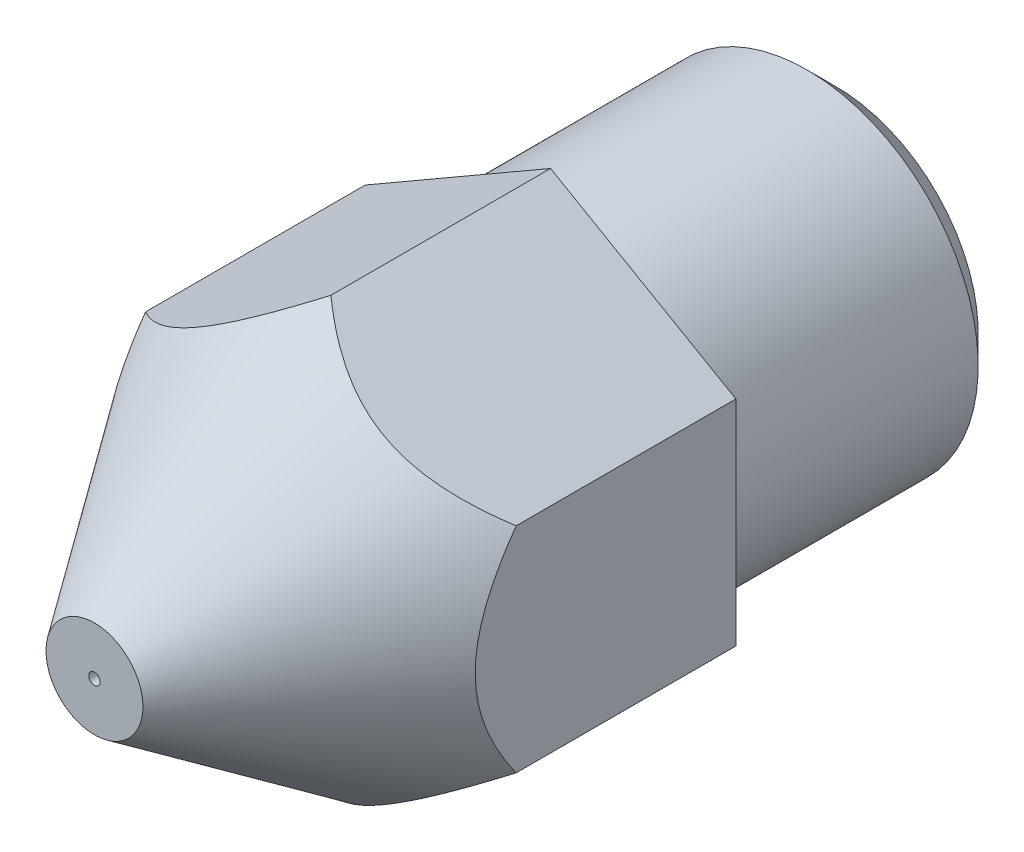
from build123d import *

# Parameters (mm, degrees)
SKETCH2_R          = 11.88832093
CUT_EXTRUDE2_DEPTH = 10
CHAMFER1_SIZE      = 0.5
SKETCH3_R          = 0.1
CUT_EXTRUDE3_DEPTH = 14


with BuildPart() as part:
    # Sketch1 → Revolve1 (revolve)
    with BuildSketch(Plane(origin=(0, 0, 0), x_dir=(1, 0, 0), z_dir=(0, 1, 0))):
        Polygon((1, 8.5), (3, 8.5), (3, 3.5), (4, 3.5), (4, 0), (0.85, -4.5), (0, -4.5), (0, -3.5), (1, -1.767949192), align=None)
    revolve(axis=Axis((0, 0, 0), (0, 0, 1)))

    # Sketch2 → Cut-Extrude2 (cut)
    with BuildSketch(Plane(origin=(0, 0, -3.5), x_dir=(-1, 0, 0), z_dir=(0, 0, -1))):
        Circle(SKETCH2_R)
        Polygon((3.25, 1.876388375), (0, 3.75277675), (-3.25, 1.876388375), (-3.25, -1.876388375), (0, -3.75277675), (3.25, -1.876388375), align=None, mode=Mode.SUBTRACT)
    extrude(amount=-CUT_EXTRUDE2_DEPTH, mode=Mode.SUBTRACT)

    # Chamfer1
    chamfer1_edges = [part.edges().sort_by_distance(p)[0] for p in [
        (-3, 0, -8.5),
    ]]
    chamfer(chamfer1_edges, length=CHAMFER1_SIZE)

    # Sketch3 → Cut-Extrude3 (cut, through all)
    with BuildSketch(Plane.XY.offset(4.5)):
        Circle(SKETCH3_R)
    extrude(amount=-CUT_EXTRUDE3_DEPTH, mode=Mode.SUBTRACT)


solid = part.part
